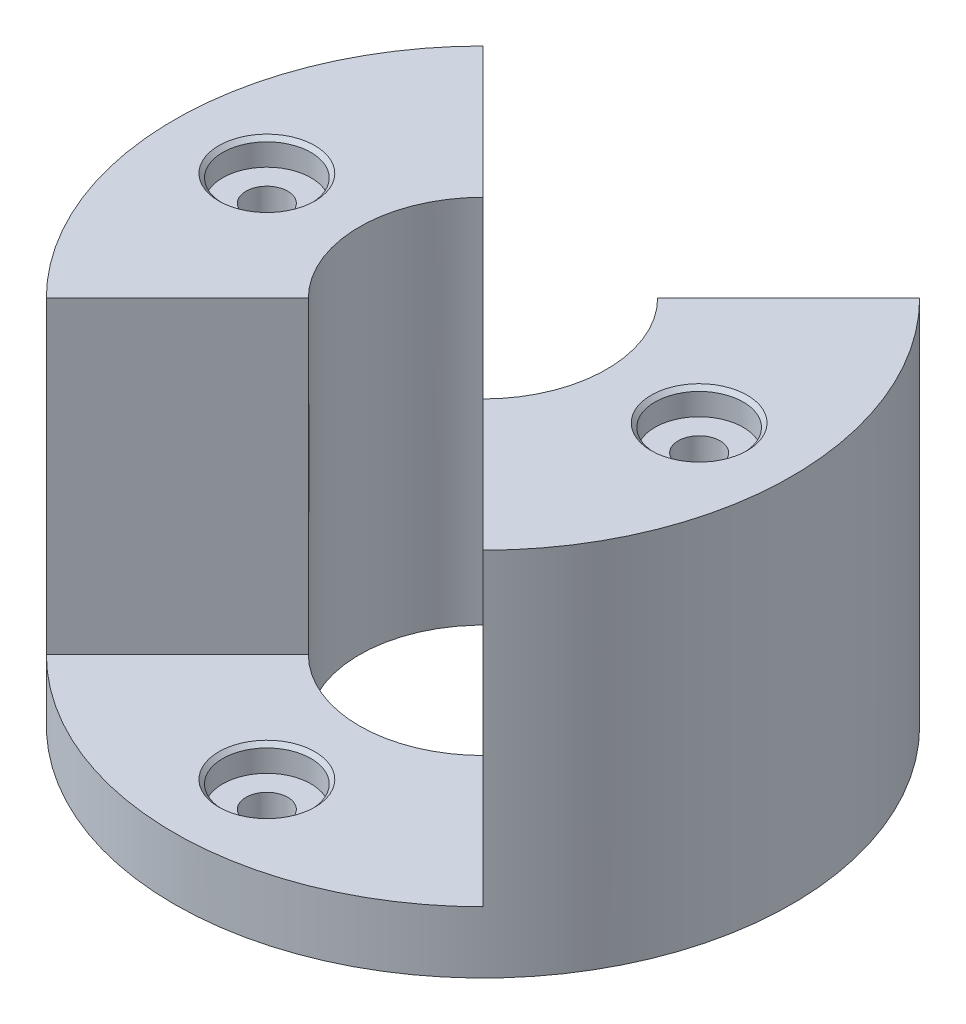
from build123d import *

# Parameters (mm, degrees)
SKETCH3_R                              = 50
BOSS_EXTRUDE1_DEPTH                    = 10
SKETCH4_R                              = 20
CUT_EXTRUDE3_DEPTH                     = 10
BOSS_EXTRUDE3_DEPTH                    = 50
CBORE_FOR_M6_HEX_HEAD_BOLT1_AT_2_COUNT = 2
CBORE_FOR_M6_HEX_HEAD_BOLT1_AT_2_PITCH = 70
CBORE_FOR_M6_HEX_HEAD_BOLT4_AT_2_COUNT = 2
CBORE_FOR_M6_HEX_HEAD_BOLT4_AT_2_PITCH = 70


with BuildPart() as part:
    # Sketch3 → Boss-Extrude1 (new body)
    with BuildSketch(Plane(origin=(0, 0, 0), x_dir=(1, 0, 0), z_dir=(0, 1, 0))):
        Circle(SKETCH3_R)
    extrude(amount=BOSS_EXTRUDE1_DEPTH)

    # Sketch4 → Cut-Extrude3 (cut)
    with BuildSketch(Plane(origin=(0, 10, 0), x_dir=(1, 0, 0), z_dir=(0, 1, 0))):
        Circle(SKETCH4_R)
    extrude(amount=-CUT_EXTRUDE3_DEPTH, mode=Mode.SUBTRACT)

    # Sketch5 → Boss-Extrude3 (add)
    with BuildSketch(Plane(origin=(0, 10, 0), x_dir=(1, 0, 0), z_dir=(0, 1, 0))):
        with BuildLine():
            ThreePointArc((14.142135624, 14.142135624), (20, 0), (14.142135624, -14.142135624))
            Line((14.142135624, -14.142135624), (35.355339059, -35.355339059))
            ThreePointArc((35.355339059, -35.355339059), (50, 0), (35.355339059, 35.355339059))
            Line((35.355339059, 35.355339059), (14.142135624, 14.142135624))
        make_face()
        with BuildLine():
            ThreePointArc((-14.142135624, -14.142135624), (-20, 0), (-14.142135624, 14.142135624))
            Line((-14.142135624, 14.142135624), (-35.355339059, 35.355339059))
            ThreePointArc((-35.355339059, 35.355339059), (-50, 0), (-35.355339059, -35.355339059))
            Line((-35.355339059, -35.355339059), (-14.142135624, -14.142135624))
        make_face()
    extrude(amount=BOSS_EXTRUDE3_DEPTH)

    # Sketch7 → CBORE for M6 Hex Head Bolt1 (revolve, cut)
    with BuildSketch(Plane(origin=(-35, 60, 0), x_dir=(0, 0, 1), z_dir=(1, 0, 0))):
        Polygon((0, 0), (0, 60), (3.38, 60), (3.38, 4.19), (7.145, 4.19), (7.145, 0.635), (7.78, 0), align=None)
    cbore_for_m6_hex_head_bolt1 = revolve(axis=Axis((-35, 66.35, 0), (0, -1, 0)), mode=Mode.SUBTRACT)

    # CBORE for M6 Hex Head Bolt1 at 2: CBORE for M6 Hex Head Bolt1 ×2
    with Locations(*[(i * CBORE_FOR_M6_HEX_HEAD_BOLT1_AT_2_PITCH, 0, 0) for i in range(1, CBORE_FOR_M6_HEX_HEAD_BOLT1_AT_2_COUNT)]):
        add(cbore_for_m6_hex_head_bolt1, mode=Mode.SUBTRACT)

    # Sketch17 → CBORE for M6 Hex Head Bolt4 (revolve, cut)
    with BuildSketch(Plane(origin=(0, 10, -35), x_dir=(0, 0, 1), z_dir=(1, 0, 0))):
        Polygon((0, 0), (0, 10), (3.38, 10), (3.38, 4.19), (7.145, 4.19), (7.145, 0.635), (7.78, 0), align=None)
    cbore_for_m6_hex_head_bolt4 = revolve(axis=Axis((0, 16.35, -35), (0, -1, 0)), mode=Mode.SUBTRACT)

    # CBORE for M6 Hex Head Bolt4 at 2: CBORE for M6 Hex Head Bolt4 ×2
    with Locations(*[(0, 0, i * CBORE_FOR_M6_HEX_HEAD_BOLT4_AT_2_PITCH) for i in range(1, CBORE_FOR_M6_HEX_HEAD_BOLT4_AT_2_COUNT)]):
        add(cbore_for_m6_hex_head_bolt4, mode=Mode.SUBTRACT)


solid = part.part
